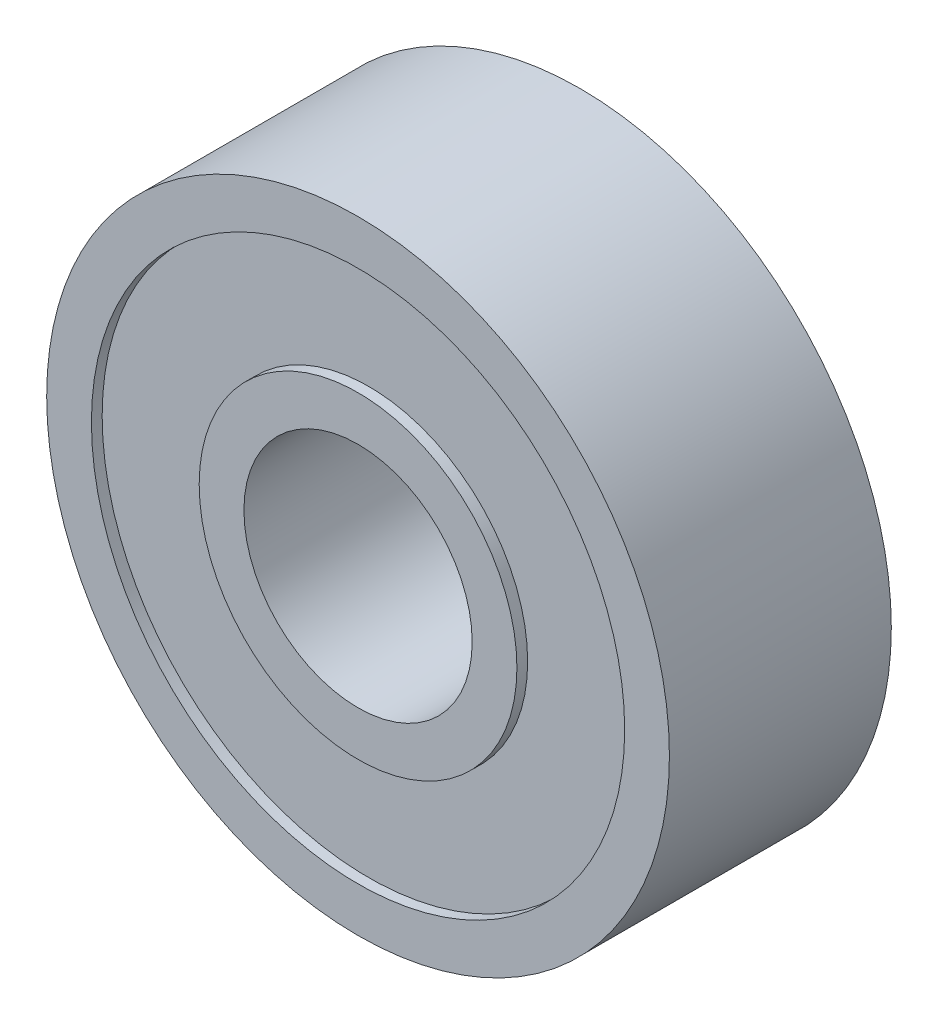
from build123d import *

# Parameters (mm, degrees)
SKETCH1_R           = 11.049
SKETCH1_R_2         = 4.05
BOSS_EXTRUDE1_DEPTH = 3.937
SKETCH2_R           = 9.4615
SKETCH2_R_2         = 5.6375
CUT_EXTRUDE1_DEPTH  = 0.381


with BuildPart() as part:
    # Sketch1 → Boss-Extrude1 (new body, symmetric)
    with BuildSketch(Plane.XY):
        Circle(SKETCH1_R)
        Circle(SKETCH1_R_2, mode=Mode.SUBTRACT)
    extrude(amount=BOSS_EXTRUDE1_DEPTH, both=True)

    # Sketch2 → Cut-Extrude1 (cut)
    with BuildSketch(Plane.XY.offset(3.937)):
        Circle(SKETCH2_R)
        Circle(SKETCH2_R_2, mode=Mode.SUBTRACT)
    cut_extrude1 = extrude(amount=-CUT_EXTRUDE1_DEPTH, mode=Mode.SUBTRACT)

    # Mirror1: Cut-Extrude1 across plane
    add(cut_extrude1.mirror(Plane.XY), mode=Mode.SUBTRACT)


solid = part.part
